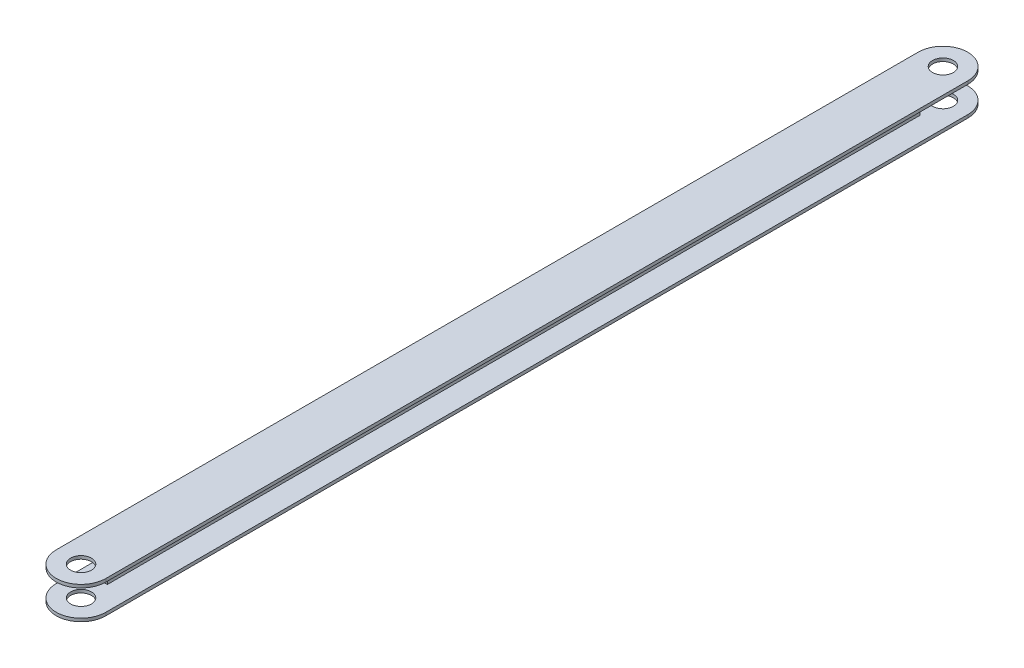
from build123d import *

# Parameters (mm, degrees)
SKETCH1_W           = 1.2
SKETCH1_H           = 10
SKETCH1_W_2         = 19
SKETCH1_H_2         = 1.2
BOSS_EXTRUDE1_DEPTH = 349
SKETCH3_R           = 4
CUT_EXTRUDE2_DEPTH  = 370
SKETCH6_W           = 18.962067398
SKETCH6_H           = 10
CUT_EXTRUDE4_DEPTH  = 370
SKETCH10_W          = 1.2
SKETCH10_H          = 10
CUT_EXTRUDE5_DEPTH  = 105


with BuildPart() as part:
    # Sketch1 → Boss-Extrude1 (new body)
    with BuildSketch(Plane.XY):
        Rectangle(SKETCH1_W, SKETCH1_H)
        with Locations((0, -5.6)):
            Rectangle(SKETCH1_W_2, SKETCH1_H_2)
        with Locations((0, 5.6)):
            Rectangle(SKETCH1_W_2, SKETCH1_H_2)
    extrude(amount=BOSS_EXTRUDE1_DEPTH)

    # Sketch3 → Cut-Extrude2 (cut)
    with BuildSketch(Plane(origin=(0, 6.2, 0), x_dir=(1, 0, 0), z_dir=(0, 1, 0))):
        with BuildLine():
            Line((-9.5, 0), (-9.5, -9.5))
            ThreePointArc((-9.5, -9.5), (-6.717514436, -2.782485594), (-4.2e-08, 0))
            Line((-4.2e-08, 0), (-9.5, 0))
        make_face()
        with BuildLine():
            Line((9.5, 0), (-4.2e-08, 0))
            ThreePointArc((-4.2e-08, 0), (6.717514406, -2.782485564), (9.5, -9.5))
            Line((9.5, -9.5), (9.5, 0))
        make_face()
        with BuildLine():
            ThreePointArc((14.5, -9.5), (0, 5), (-14.5, -9.5))
            Line((-14.5, -9.5), (-9.5, -9.5))
            Line((-9.5, -9.5), (-9.5, 0))
            Line((-9.5, 0), (-4.2e-08, 0))
            Line((-4.2e-08, 0), (9.5, 0))
            Line((9.5, 0), (9.5, -9.5))
            Line((9.5, -9.5), (14.5, -9.5))
        make_face()
        with Locations((0, -9.5)):
            Circle(SKETCH3_R)
    cut_extrude2 = extrude(amount=-CUT_EXTRUDE2_DEPTH, mode=Mode.SUBTRACT)

    # Mirror1: Cut-Extrude2 across plane
    add(cut_extrude2.mirror(Plane.XY.offset(174.5)), mode=Mode.SUBTRACT)

    # Sketch6 → Cut-Extrude4 (cut)
    with BuildSketch(Plane.ZY.offset(0.6)):
        with Locations((9.5, 0)):
            Rectangle(SKETCH6_W, SKETCH6_H)
    extrude(amount=-CUT_EXTRUDE4_DEPTH, mode=Mode.SUBTRACT)

    # Sketch10 → Cut-Extrude5 (cut)
    with BuildSketch(Plane(origin=(0, 0, 18.981033699), x_dir=(-1, 0, 0), z_dir=(0, 0, -1))):
        Rectangle(SKETCH10_W, SKETCH10_H)
    cut_extrude5 = extrude(amount=CUT_EXTRUDE5_DEPTH, mode=Mode.SUBTRACT)

    # Mirror2: Cut-Extrude5 across plane
    add(cut_extrude5.mirror(Plane.XY.offset(174.5)), mode=Mode.SUBTRACT)


solid = part.part
